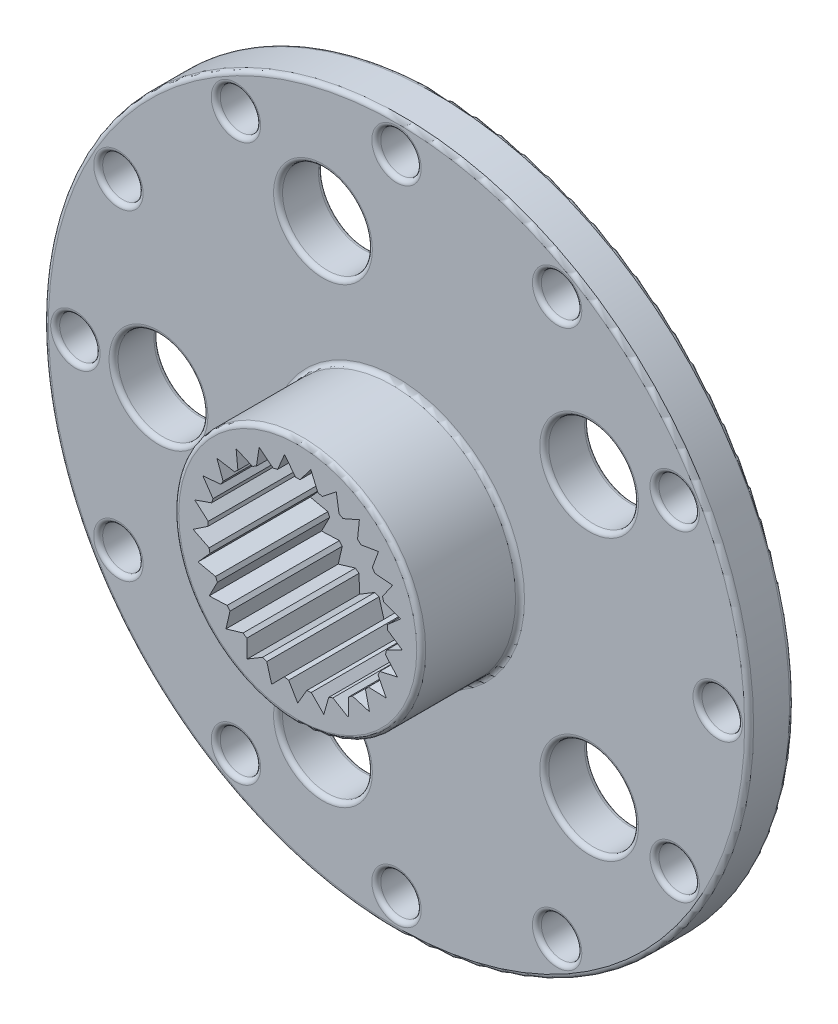
from build123d import *

# Parameters (mm, degrees)
ESQUISSE1_R                = 7.85
BOSS_EXTRU_1_DEPTH         = 1
ESQUISSE2_R                = 2.75
BOSS_EXTRU_2_DEPTH         = 2.2
ESQUISSE3_R                = 2
ENL_V_MAT_EXTRU_1_DEPTH    = 2.5
CUT_EXTRUDE1_DEPTH         = 2.5
CIRPATTERN1_COUNT          = 25
ESQUISSE4_R                = 1.6
ENL_V_MAT_EXTRU_2_DEPTH    = 0.4
ESQUISSE5_R                = 0.85
ENL_V_MAT_EXTRU_3_DEPTH    = 4.8
F_0_9_0_9_DIAMETER_HOLE1_D = 0.9
CIRPATTERN2_COUNT          = 12
F_2_0_2_DIAMETER_HOLE1_D   = 2
CIRPATTERN3_COUNT          = 5
FILLET1_R                  = 0.1


with BuildPart() as part:
    # Esquisse1 → Boss.-Extru.1 (new body)
    with BuildSketch(Plane.XY):
        Circle(ESQUISSE1_R)
    extrude(amount=BOSS_EXTRU_1_DEPTH)

    # Esquisse2 → Boss.-Extru.2 (add)
    with BuildSketch(Plane.XY.offset(1)):
        Circle(ESQUISSE2_R)
    extrude(amount=BOSS_EXTRU_2_DEPTH)

    # Esquisse3 → Enlèv. mat.-Extru.1 (cut)
    with BuildSketch(Plane.XY.offset(3.2)):
        Circle(ESQUISSE3_R)
    extrude(amount=-ENL_V_MAT_EXTRU_1_DEPTH, mode=Mode.SUBTRACT)

    # Sketch1 → Cut-Extrude1 (cut)
    with BuildSketch(Plane.XY.offset(3.2)):
        with BuildLine():
            Line((0.20072343, -1.989902034), (0, -2.334))
            Line((0, -2.334), (-0.20072343, -1.989902034))
            ThreePointArc((-0.20072343, -1.989902034), (0, -2), (0.20072343, -1.989902034))
        make_face()
    cut_extrude1 = extrude(amount=-CUT_EXTRUDE1_DEPTH, mode=Mode.SUBTRACT)

    # CirPattern1: Cut-Extrude1 ×25 about axis
    cirpattern1_axis = Axis((0, 0, 0), (0, 0, 1))
    for i in range(1, CIRPATTERN1_COUNT):
        add(cut_extrude1.rotate(cirpattern1_axis, i * 360 / CIRPATTERN1_COUNT), mode=Mode.SUBTRACT)

    # Esquisse4 → Enlèv. mat.-Extru.2 (cut)
    with BuildSketch(Plane(origin=(0, 0, 0), x_dir=(-1, 0, 0), z_dir=(0, 0, -1))):
        Circle(ESQUISSE4_R)
    extrude(amount=-ENL_V_MAT_EXTRU_2_DEPTH, mode=Mode.SUBTRACT)

    # Esquisse5 → Enlèv. mat.-Extru.3 (cut)
    with BuildSketch(Plane(origin=(0, 0, 0.4), x_dir=(-1, 0, 0), z_dir=(0, 0, -1))):
        Circle(ESQUISSE5_R)
    extrude(amount=-ENL_V_MAT_EXTRU_3_DEPTH, mode=Mode.SUBTRACT)

    # Ø0.9 (0.9) Diameter Hole1 (through all)
    with Locations(Plane(origin=(0, 0, 0), x_dir=(-1, 0, 0), z_dir=(0, 0, -1))):
        with Locations((7.15, 0)):
            f_0_9_0_9_diameter_hole1 = Hole(F_0_9_0_9_DIAMETER_HOLE1_D / 2)

    # CirPattern2: Ø0.9 (0.9) Diameter Hole1 ×12 about axis
    cirpattern2_axis = Axis((0, 0, 0), (0, 0, 1))
    for i in range(1, CIRPATTERN2_COUNT):
        add(f_0_9_0_9_diameter_hole1.rotate(cirpattern2_axis, i * 360 / CIRPATTERN2_COUNT), mode=Mode.SUBTRACT)

    # Ø2.0 (2) Diameter Hole1 (through all)
    with Locations(Plane(origin=(0, 0, 0), x_dir=(-1, 0, 0), z_dir=(0, 0, -1))):
        with Locations((5.3, 0)):
            f_2_0_2_diameter_hole1 = Hole(F_2_0_2_DIAMETER_HOLE1_D / 2)

    # CirPattern3: Ø2.0 (2) Diameter Hole1 ×5 about axis
    cirpattern3_axis = Axis((0, 0, 0), (0, 0, 1))
    for i in range(1, CIRPATTERN3_COUNT):
        add(f_2_0_2_diameter_hole1.rotate(cirpattern3_axis, i * 360 / CIRPATTERN3_COUNT), mode=Mode.SUBTRACT)

    # Fillet1
    fillet1_edges = [part.edges().sort_by_distance(p)[0] for p in [
        (-7.85, 0, 0),
        (1.6, 0, 0),
        (-7.6, 0, 1),
        (-7.6, 0, 0),
        (-6.581793069, 3.8, 1),
        (-6.581793069, 3.8, 0),
        (-3.8, 6.581793069, 1),
        (-3.8, 6.581793069, 0),
        (0, 7.6, 1),
        (0, 7.6, 0),
        (3.8, 6.581793069, 1),
        (3.8, 6.581793069, 0),
        (6.581793069, 3.8, 1),
        (6.581793069, 3.8, 0),
        (7.6, 0, 1),
        (7.6, 0, 0),
        (6.581793069, -3.8, 1),
        (6.581793069, -3.8, 0),
        (3.8, -6.581793069, 1),
        (3.8, -6.581793069, 0),
        (0, -7.6, 1),
        (0, -7.6, 0),
        (-3.8, -6.581793069, 1),
        (-3.8, -6.581793069, 0),
        (-6.581793069, -3.8, 1),
        (-6.581793069, -3.8, 0),
        (-6.3, 0, 1),
        (-6.3, 0, 0),
        (-1.946807065, 5.991656053, 1),
        (-1.946807065, 5.991656053, 0),
        (5.096807065, 3.703047089, 1),
        (5.096807065, 3.703047089, 0),
        (5.096807065, -3.703047089, 1),
        (5.096807065, -3.703047089, 0),
        (-1.946807065, -5.991656053, 1),
        (-1.946807065, -5.991656053, 0),
        (-7.85, 0, 1),
        (-2.75, 0, 1),
        (-2.75, 0, 3.2),
    ]]
    fillet(fillet1_edges, radius=FILLET1_R)


solid = part.part
